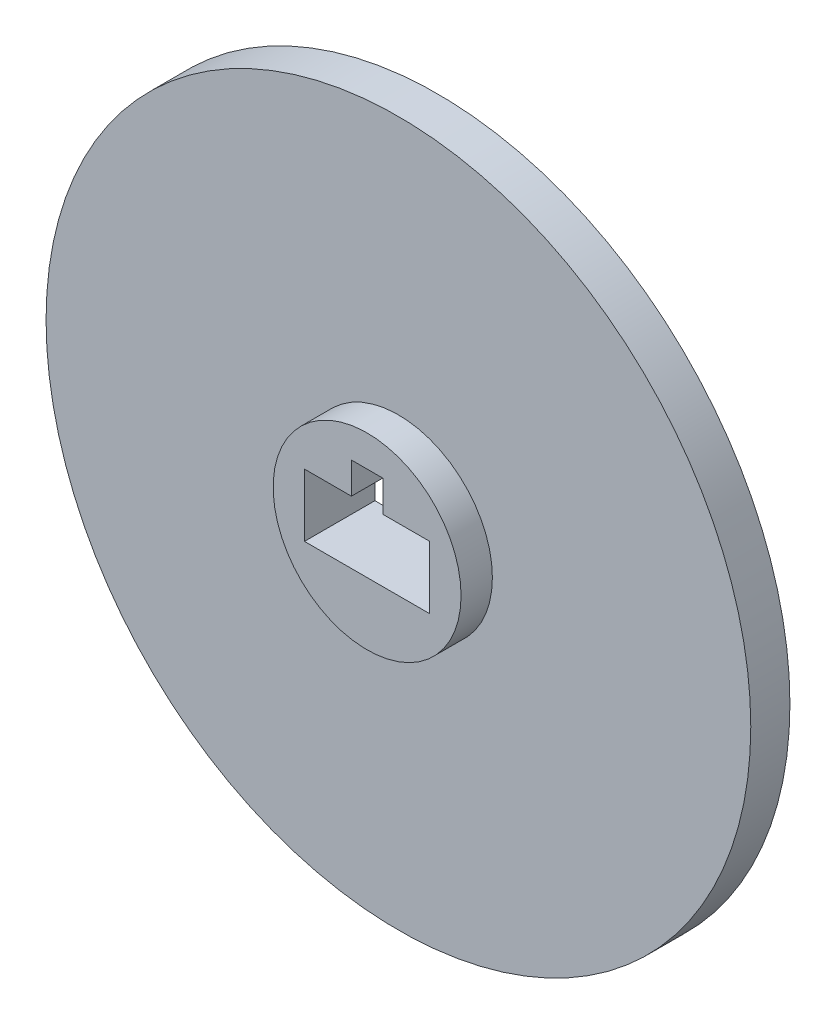
from build123d import *

# Parameters (mm, degrees)
SKETCH1_R           = 22.5
BOSS_EXTRUDE1_DEPTH = 2.5
SKETCH2_R           = 6
BOSS_EXTRUDE2_DEPTH = 2
CUT_EXTRUDE1_DEPTH  = 10


with BuildPart() as part:
    # Sketch1 → Boss-Extrude1 (new body)
    with BuildSketch(Plane.XY):
        Circle(SKETCH1_R)
    extrude(amount=BOSS_EXTRUDE1_DEPTH)

    # Sketch2 → Boss-Extrude2 (add)
    with BuildSketch(Plane.XY.offset(2.5)):
        Circle(SKETCH2_R)
    extrude(amount=BOSS_EXTRUDE2_DEPTH)

    # Sketch3 → Cut-Extrude1 (cut)
    with BuildSketch(Plane.XY.offset(4.5)):
        Polygon((-4, 2), (-4, -2), (4, -2), (4, 2), (1, 2), (1, 4), (-1, 4), (-1, 2), align=None)
    extrude(amount=-CUT_EXTRUDE1_DEPTH, mode=Mode.SUBTRACT)


solid = part.part
